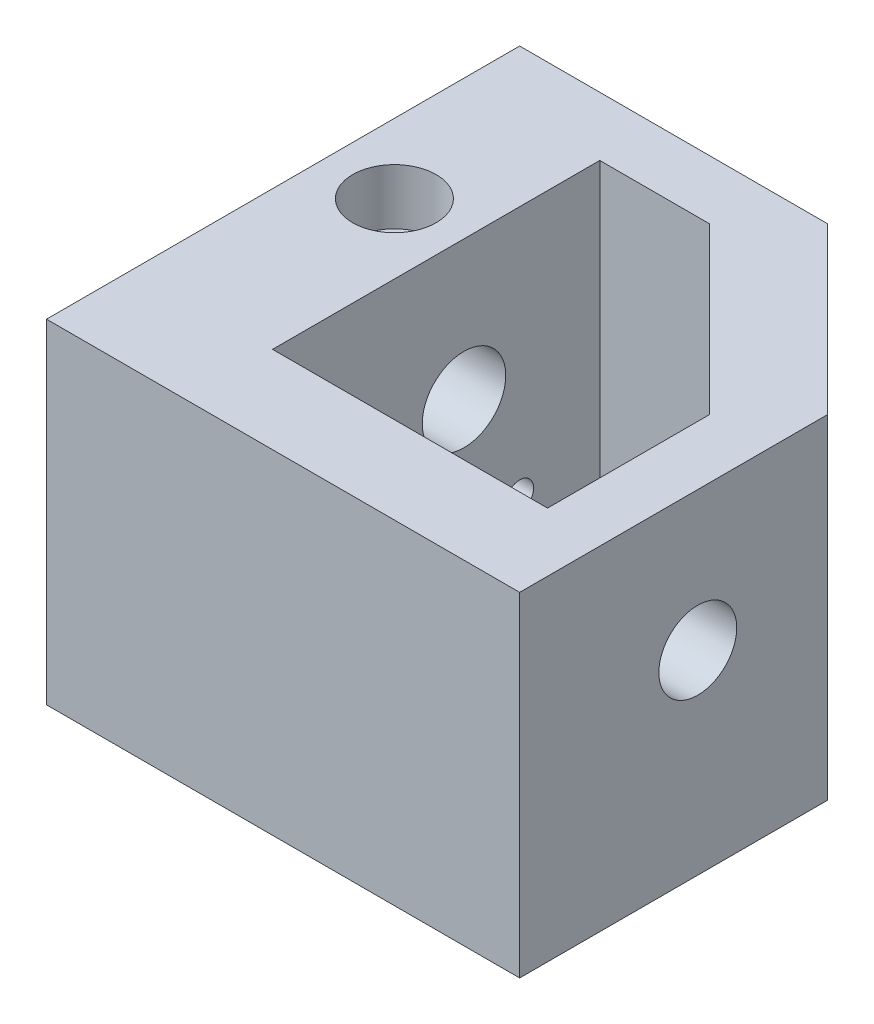
from build123d import *

# Parameters (mm, degrees)
BOSS_EXTRUDE2_DEPTH = 60
BOSS_EXTRUDE3_DEPTH = 10
CUT_EXTRUDE2_REACH  = 97.673
SKETCH8_R           = 4.75
SKETCH8_R_2         = 3
CUT_EXTRUDE3_REACH  = 87
SKETCH9_R           = 7.5
CUT_EXTRUDE4_REACH  = 87
SKETCH10_R          = 7
SKETCH12_R          = 7.5
CUT_EXTRUDE6_DEPTH  = 10
CUT_EXTRUDE16_REACH = 52
SKETCH24_R          = 2.25
SKETCH33_R          = 1.5
CUT_EXTRUDE18_DEPTH = 10
SKETCH37_W          = 85
SKETCH37_H          = 60
BOSS_EXTRUDE7_DEPTH = 5
SKETCH38_R          = 2.5
SKETCH38_R_2        = 2
CUT_EXTRUDE19_DEPTH = 20
CUT_EXTRUDE20_REACH = 87
SKETCH39_R          = 2.5
SKETCH40_R          = 2
CUT_EXTRUDE21_DEPTH = 10
SKETCH41_R          = 1.15
CUT_EXTRUDE22_DEPTH = 2.5


with BuildPart() as part:
    # Sketch1 → Boss-Extrude2 (new body)
    with BuildSketch(Plane(origin=(0, 0, 0), x_dir=(1, 0, 0), z_dir=(0, 1, 0))):
        Polygon((-42.705817414, 39.602616449), (-42.705817414, -40.397383551), (42.294182586, -40.397383551), (42.294182586, 9.904131639), (12.595697776, 39.602616449), align=None)
        Polygon((-17.705817414, 28.992616449), (-17.705817414, -29.787383551), (31.69097915, -29.787383551), (31.69097915, -0.705868361), (1.992494341, 28.992616449), align=None, mode=Mode.SUBTRACT)
    extrude(amount=BOSS_EXTRUDE2_DEPTH)

    # Sketch4 → Boss-Extrude3 (add)
    with BuildSketch(Plane(origin=(0, 0, 0), x_dir=(-1, 0, 0), z_dir=(0, -1, 0))):
        Polygon((17.705817414, 28.992616449), (-1.992494341, 28.992616449), (-31.69097915, -0.705868361), (-31.69097915, -29.787383551), (17.705817414, -29.787383551), align=None)
    extrude(amount=-BOSS_EXTRUDE3_DEPTH)

    # Sketch8 → Cut-Extrude2 (cut, up to next)
    with BuildSketch(Plane(origin=(26.099157113, 0, -26.099157113), x_dir=(-0.707106781, 0, -0.707106781), z_dir=(0.707106781, 0, -0.707106781)), mode=Mode.PRIVATE) as cut_extrude2_sk1:
        with Locations((11.096775332, 48)):
            Circle(SKETCH8_R)
    cut_extrude2_tool1 = extrude(cut_extrude2_sk1.sketch, amount=-CUT_EXTRUDE2_REACH, mode=Mode.PRIVATE) & part.part
    add(cut_extrude2_tool1.solids().sort_by_distance((18.252552, 48, -33.945762))[0], mode=Mode.SUBTRACT)
    # Sketch8 → Cut-Extrude2 (cut, up to next)
    with BuildSketch(Plane(origin=(26.099157113, 0, -26.099157113), x_dir=(-0.707106781, 0, -0.707106781), z_dir=(0.707106781, 0, -0.707106781)), mode=Mode.PRIVATE) as cut_extrude2_sk2:
        with Locations((11.096775332, 34)):
            Circle(SKETCH8_R_2)
    cut_extrude2_tool2 = extrude(cut_extrude2_sk2.sketch, amount=-CUT_EXTRUDE2_REACH, mode=Mode.PRIVATE) & part.part
    add(cut_extrude2_tool2.solids().sort_by_distance((18.252552, 34, -33.945762))[0], mode=Mode.SUBTRACT)
    # Sketch8 → Cut-Extrude2 (cut, up to next)
    with BuildSketch(Plane(origin=(26.099157113, 0, -26.099157113), x_dir=(-0.707106781, 0, -0.707106781), z_dir=(0.707106781, 0, -0.707106781)), mode=Mode.PRIVATE) as cut_extrude2_sk3:
        with Locations((11.096775332, 22)):
            Circle(SKETCH8_R)
    cut_extrude2_tool3 = extrude(cut_extrude2_sk3.sketch, amount=-CUT_EXTRUDE2_REACH, mode=Mode.PRIVATE) & part.part
    add(cut_extrude2_tool3.solids().sort_by_distance((18.252552, 22, -33.945762))[0], mode=Mode.SUBTRACT)
    # Sketch8 → Cut-Extrude2 (cut, up to next)
    with BuildSketch(Plane(origin=(26.099157113, 0, -26.099157113), x_dir=(-0.707106781, 0, -0.707106781), z_dir=(0.707106781, 0, -0.707106781)), mode=Mode.PRIVATE) as cut_extrude2_sk4:
        with Locations((-0.903224668, 22)):
            Circle(SKETCH8_R_2)
    cut_extrude2_tool4 = extrude(cut_extrude2_sk4.sketch, amount=-CUT_EXTRUDE2_REACH, mode=Mode.PRIVATE) & part.part
    add(cut_extrude2_tool4.solids().sort_by_distance((26.737833, 22, -25.460481))[0], mode=Mode.SUBTRACT)
    # Sketch8 → Cut-Extrude2 (cut, up to next)
    with BuildSketch(Plane(origin=(26.099157113, 0, -26.099157113), x_dir=(-0.707106781, 0, -0.707106781), z_dir=(0.707106781, 0, -0.707106781)), mode=Mode.PRIVATE) as cut_extrude2_sk5:
        with Locations((-14.903224668, 22)):
            Circle(SKETCH8_R)
    cut_extrude2_tool5 = extrude(cut_extrude2_sk5.sketch, amount=-CUT_EXTRUDE2_REACH, mode=Mode.PRIVATE) & part.part
    add(cut_extrude2_tool5.solids().sort_by_distance((36.637328, 22, -15.560986))[0], mode=Mode.SUBTRACT)

    # Sketch9 → Cut-Extrude3 (cut, up to next)
    with BuildSketch(Plane.ZY.offset(42.705817414), mode=Mode.PRIVATE) as cut_extrude3_sk1:
        with Locations((-4.602616449, 35)):
            Circle(SKETCH9_R)
    cut_extrude3_tool1 = extrude(cut_extrude3_sk1.sketch, amount=-CUT_EXTRUDE3_REACH, mode=Mode.PRIVATE) & part.part
    add(cut_extrude3_tool1.solids().sort_by_distance((-42.705817, 35, -4.602616))[0], mode=Mode.SUBTRACT)

    # Sketch10 → Cut-Extrude4 (cut, up to next)
    with BuildSketch(Plane(origin=(42.294182586, 0, 0), x_dir=(0, 0, -1), z_dir=(1, 0, 0)), mode=Mode.PRIVATE) as cut_extrude4_sk1:
        with Locations((-13.397383551, 35)):
            Circle(SKETCH10_R)
    cut_extrude4_tool1 = extrude(cut_extrude4_sk1.sketch, amount=-CUT_EXTRUDE4_REACH, mode=Mode.PRIVATE) & part.part
    add(cut_extrude4_tool1.solids().sort_by_distance((42.294183, 35, 13.397384))[0], mode=Mode.SUBTRACT)

    # Sketch12 → Cut-Extrude6 (cut)
    with BuildSketch(Plane(origin=(0, 60, 0), x_dir=(1, 0, 0), z_dir=(0, 1, 0))):
        with Locations((-30.205817414, 4.602616449)):
            Circle(SKETCH12_R)
    extrude(amount=-CUT_EXTRUDE6_DEPTH, mode=Mode.SUBTRACT)

    # Sketch24 → Cut-Extrude16 (cut, up to next)
    with BuildSketch(Plane(origin=(0, 50, 0), x_dir=(1, 0, 0), z_dir=(0, 1, 0)), mode=Mode.PRIVATE) as cut_extrude16_sk1:
        with Locations((-26.455817414, 4.602616449)):
            Circle(SKETCH24_R)
    cut_extrude16_tool1 = extrude(cut_extrude16_sk1.sketch, amount=-CUT_EXTRUDE16_REACH, mode=Mode.PRIVATE) & part.part
    add(cut_extrude16_tool1.solids().sort_by_distance((-26.455817, 50, -4.602616))[0], mode=Mode.SUBTRACT)
    # Sketch24 → Cut-Extrude16 (cut, up to next)
    with BuildSketch(Plane(origin=(0, 50, 0), x_dir=(1, 0, 0), z_dir=(0, 1, 0)), mode=Mode.PRIVATE) as cut_extrude16_sk2:
        with Locations((-33.955817414, 4.602616449)):
            Circle(SKETCH24_R)
    cut_extrude16_tool2 = extrude(cut_extrude16_sk2.sketch, amount=-CUT_EXTRUDE16_REACH, mode=Mode.PRIVATE) & part.part
    add(cut_extrude16_tool2.solids().sort_by_distance((-33.955817, 50, -4.602616))[0], mode=Mode.SUBTRACT)

    # Sketch33 → Cut-Extrude18 (cut)
    with BuildSketch(Plane.ZY.offset(42.705817414)):
        with Locations((5.397383551, 38)):
            Circle(SKETCH33_R)
        with Locations((5.397383551, 32)):
            Circle(SKETCH33_R)
    extrude(amount=-CUT_EXTRUDE18_DEPTH, mode=Mode.SUBTRACT)

    # Sketch37 → Boss-Extrude7 (add)
    with BuildSketch(Plane.XY.offset(40.397383551)):
        with Locations((-0.205817414, 30)):
            Rectangle(SKETCH37_W, SKETCH37_H)
    extrude(amount=BOSS_EXTRUDE7_DEPTH)

    # Sketch38 → Cut-Extrude19 (cut)
    with BuildSketch(Plane.ZY.offset(42.705817414)):
        with Locations((-19.602616449, 5)):
            Circle(SKETCH38_R)
        with Locations((25.397383551, 5)):
            Circle(SKETCH38_R)
        with Locations((-36.852616449, 40)):
            Circle(SKETCH38_R_2)
        with Locations((42.647383551, 40)):
            Circle(SKETCH38_R_2)
    extrude(amount=-CUT_EXTRUDE19_DEPTH, mode=Mode.SUBTRACT)

    # Sketch39 → Cut-Extrude20 (cut, up to next)
    with BuildSketch(Plane.ZY.offset(42.705817414), mode=Mode.PRIVATE) as cut_extrude20_sk1:
        with Locations((-14.602616449, 15)):
            Circle(SKETCH39_R)
    cut_extrude20_tool1 = extrude(cut_extrude20_sk1.sketch, amount=-CUT_EXTRUDE20_REACH, mode=Mode.PRIVATE) & part.part
    add(cut_extrude20_tool1.solids().sort_by_distance((-42.705817, 15, -14.602616))[0], mode=Mode.SUBTRACT)

    # Sketch40 → Cut-Extrude21 (cut)
    with BuildSketch(Plane.XZ):
        with Locations((-36.705817414, -33.602616449)):
            Circle(SKETCH40_R)
        with Locations((-36.705817414, 39.397383551)):
            Circle(SKETCH40_R)
        with Locations((36.294182586, 39.397383551)):
            Circle(SKETCH40_R)
        with Locations((36.294182586, -7.418850265)):
            Circle(SKETCH40_R)
        with Locations((10.110416402, -33.602616449)):
            Circle(SKETCH40_R)
    extrude(amount=-CUT_EXTRUDE21_DEPTH, mode=Mode.SUBTRACT)

    # Sketch41 → Cut-Extrude22 (cut)
    with BuildSketch(Plane(origin=(26.099157113, 0, -26.099157113), x_dir=(-0.707106781, 0, -0.707106781), z_dir=(0.707106781, 0, -0.707106781))):
        with Locations((14.096775332, 34)):
            Circle(SKETCH41_R)
        with Locations((8.096775332, 34)):
            Circle(SKETCH41_R)
        with Locations((-0.903224668, 25)):
            Circle(SKETCH41_R)
        with Locations((-0.903224668, 19)):
            Circle(SKETCH41_R)
    extrude(amount=-CUT_EXTRUDE22_DEPTH, mode=Mode.SUBTRACT)


solid = part.part
